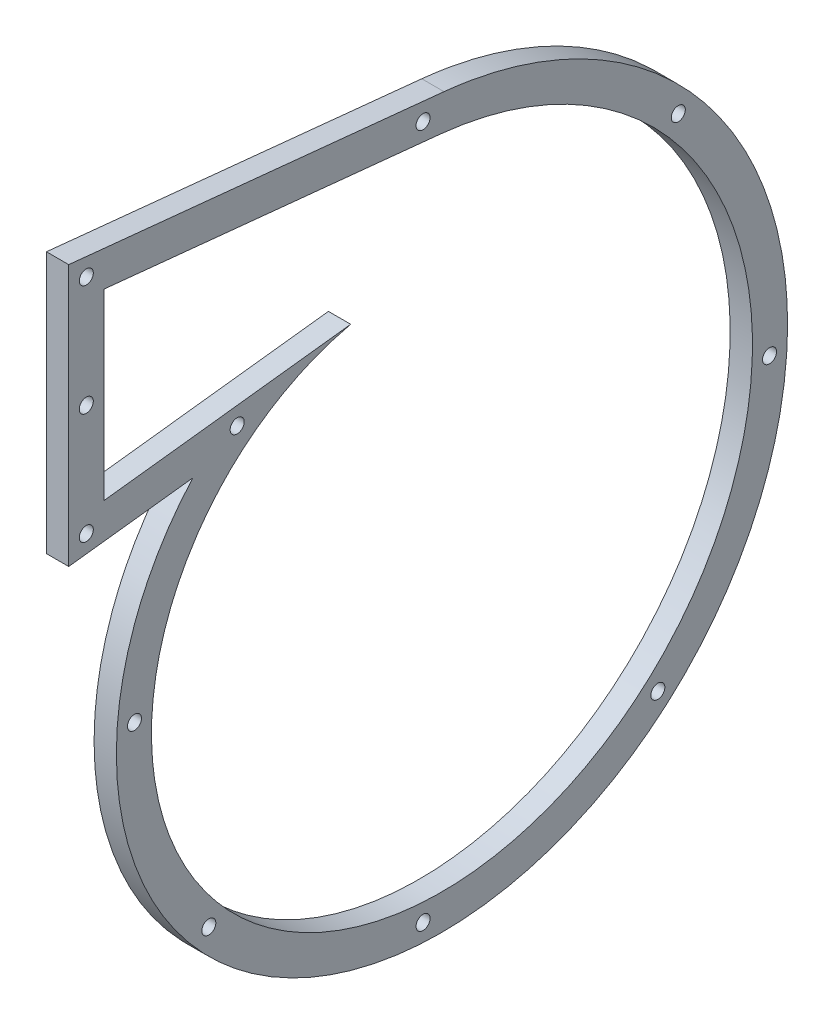
from build123d import *

# Parameters (mm, degrees)
BOSS_EXTRUDE1_DEPTH = 6.35
SKETCH11_R          = 2
CUT_EXTRUDE2_DEPTH  = 10


with BuildPart() as part:
    # Sketch10 → Boss-Extrude1 (new body)
    with BuildSketch(Plane(origin=(0, 0, 0), x_dir=(0, 0, -1), z_dir=(1, 0, 0))):
        with BuildLine():
            Line((-65.56933734, 52.009531221), (-100.935679824, 47.808985699))
            Line((-100.935679824, 47.808985699), (-100.935679824, 122.29075479))
            Line((-100.935679824, 122.29075479), (5.970340966, 111.513169224))
            add(Edge.make_bspline(
                [(5.970340966, 111.513169224), (9.050174513, 111.20267998), (15.195754527, 110.322198965), (27.224457069, 107.560584888), (41.672600889, 102.269141777), (57.583217011, 93.200335773), (76.34944741, 77.877389952), (94.274449289, 53.53377411), (104.843460982, 19.443777188), (103.677945005, -15.636484697), (91.289552438, -47.848309946), (69.405777179, -73.770277552), (40.739036605, -90.784845908), (8.654881454, -97.341351398), (-23.220610692, -93.091773694), (-51.414586087, -78.887047742), (-72.979776783, -56.641213756), (-85.804607758, -29.085280645), (-88.816261681, 0.571051967), (-83.191535024, 24.252063706), (-74.366432128, 41.075630131), (-68.698633198, 48.535069634), (-65.56933734, 52.009531221)],
                knots=[0.103071112, 0.103071112, 0.103071112, 0.103071112, 0.117085626, 0.13110014, 0.159129168, 0.187158196, 0.215187223, 0.271245279, 0.327303334, 0.38336139, 0.439419445, 0.495477501, 0.551535556, 0.607593612, 0.663651667, 0.719709723, 0.775767778, 0.831825834, 0.887883889, 0.943941945, 0.971970972, 1, 1, 1, 1], degree=3))
        make_face()
        with BuildLine():
            Line((-20.612205183, 67.419485295), (-90.935679824, 59.066997144))
            Line((-90.935679824, 59.066997144), (-90.935679824, 111.231929858))
            Line((-90.935679824, 111.231929858), (4.967288842, 101.563602076))
            add(Edge.make_bspline(
                [(-20.612205183, 67.419485295), (-24.877082573, 66.455267856), (-29.081224373, 65.085352217), (-37.21559395, 61.560478152), (-41.145637536, 59.405543875), (-48.584738117, 54.365833517), (-52.093616671, 51.481116625), (-58.554517239, 45.064659766), (-61.506373232, 41.533012683), (-66.733754258, 33.93084433), (-69.009132051, 29.860447027), (-72.785201264, 21.31099306), (-74.285770034, 16.832087637), (-76.439055333, 7.613754029), (-77.091678837, 2.874499464), (-77.504351301, -6.703367116), (-77.264340924, -11.541788953), (-75.877767223, -21.149276623), (-74.731181162, -25.918142271), (-71.549462985, -35.216137703), (-69.514346369, -39.745064349), (-64.605672967, -48.397213397), (-61.732170197, -52.520237022), (-55.227886345, -60.20508067), (-51.597196674, -63.766713581), (-43.688569666, -70.189562344), (-39.41075863, -73.050609782), (-30.343511502, -77.954720143), (-25.554232771, -79.997639846), (-15.620993672, -83.174272641), (-10.477216691, -84.30787342), (-0.008113237, -85.604846154), (5.317009901, -85.76814141), (15.965310371, -85.096533315), (21.28827135, -84.261592387), (31.744712207, -81.600321197), (36.87797025, -79.773994641), (46.77003278, -75.172055644), (51.528617832, -72.396488903), (60.495574952, -65.972727389), (64.703737934, -62.324619511), (72.409763445, -54.264994481), (75.907434968, -49.853603117), (82.054093398, -40.405990072), (84.702914605, -35.369929323), (89.040569877, -24.836599811), (90.729269998, -19.339522034), (93.066981329, -8.06752417), (93.715895777, -2.292818854), (93.929415548, 9.337436952), (93.493965482, 15.192756131), (91.531515002, 26.780331551), (90.004503349, 32.512347913), (85.890076353, 43.649598298), (83.302695164, 49.054592305), (77.136723273, 59.34149905), (73.55821175, 64.223180225), (65.515517909, 73.281690263), (61.051457803, 77.458304454), (51.376519854, 84.946163767), (46.165803684, 88.257219093), (35.165447244, 93.88079599), (29.376003057, 96.19315988), (17.40973727, 99.718780964), (11.233139789, 100.931918806), (4.967288842, 101.563602076)],
                knots=[0, 0, 0, 0, 0.03125, 0.03125, 0.0625, 0.0625, 0.09375, 0.09375, 0.125, 0.125, 0.15625, 0.15625, 0.1875, 0.1875, 0.21875, 0.21875, 0.25, 0.25, 0.28125, 0.28125, 0.3125, 0.3125, 0.34375, 0.34375, 0.375, 0.375, 0.40625, 0.40625, 0.4375, 0.4375, 0.46875, 0.46875, 0.5, 0.5, 0.53125, 0.53125, 0.5625, 0.5625, 0.59375, 0.59375, 0.625, 0.625, 0.65625, 0.65625, 0.6875, 0.6875, 0.71875, 0.71875, 0.75, 0.75, 0.78125, 0.78125, 0.8125, 0.8125, 0.84375, 0.84375, 0.875, 0.875, 0.90625, 0.90625, 0.9375, 0.9375, 0.96875, 0.96875, 1, 1, 1, 1], degree=3))
        make_face(mode=Mode.SUBTRACT)
    extrude(amount=BOSS_EXTRUDE1_DEPTH)

    # Sketch11 → Cut-Extrude2 (cut)
    with BuildSketch(Plane(origin=(6.35, 0, 0), x_dir=(0, 0, -1), z_dir=(1, 0, 0))):
        with Locations((-95.935679824, 116.761342324)):
            Circle(SKETCH11_R)
        with Locations((-95.935679824, 53.437991421)):
            Circle(SKETCH11_R)
        with Locations((-95.935679824, 85.099666873)):
            Circle(SKETCH11_R)
        with Locations((-52.956120261, 58.54277704)):
            Circle(SKETCH11_R)
        with Locations((0, -90.448962865)):
            Circle(SKETCH11_R)
        with Locations((-82.20247918, 0)):
            Circle(SKETCH11_R)
        with Locations((98.695882227, 0)):
            Circle(SKETCH11_R)
        with Locations((0, 107.089716811)):
            Circle(SKETCH11_R)
        with Locations((-61.03999449, -61.03999449)):
            Circle(SKETCH11_R)
        with Locations((66.874078846, -66.874078846)):
            Circle(SKETCH11_R)
        with Locations((72.70516699, 72.70516699)):
            Circle(SKETCH11_R)
    extrude(amount=-CUT_EXTRUDE2_DEPTH, mode=Mode.SUBTRACT)


solid = part.part
